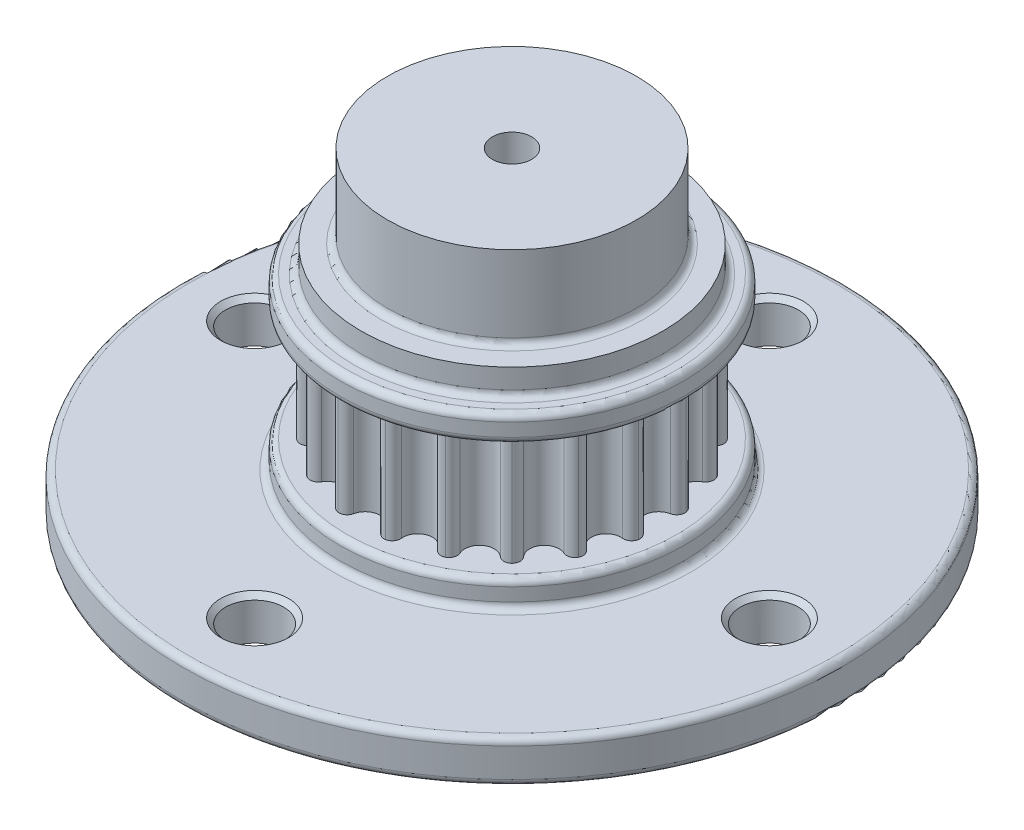
from build123d import *

# Parameters (mm, degrees)
BOSS_EXTRUDE1_DEPTH     = 3.556
CIRPATTERN1_COUNT       = 20
SKETCH2_W               = 10.342329408
SKETCH2_H               = 1.5875
SKETCH9_R               = 19.84375
SKETCH9_R_2             = 1.5
BOSS_EXTRUDE2_DEPTH     = 2.54
SKETCH3_R               = 1.74625
CUT_EXTRUDE1_DEPTH      = 6.087499985
CUT_EXTRUDE1_DEPTH_BACK = 8.627499985
CIRPATTERN2_COUNT       = 4
SKETCH11_R              = 1.5
CUT_EXTRUDE2_DEPTH      = 6
FILLET1_R               = 0.396875


with BuildPart() as part:
    # Sketch1 → Boss-Extrude1 (new body, symmetric)
    with BuildSketch(Plane(origin=(0, 0, 0), x_dir=(1, 0, 0), z_dir=(0, 1, 0))):
        with BuildLine():
            ThreePointArc((0.872060607, 8.659786465), (0.562967303, 8.148255135), (0, 7.947579308))
            ThreePointArc((0, 7.947579308), (-1.243275317, -7.849731418), (2.45593707, 7.55859709))
            ThreePointArc((2.45593707, 7.55859709), (1.982535589, 7.923417607), (1.846642263, 8.505427895))
            ThreePointArc((1.846642263, 8.505427895), (1.749626992, 8.862101959), (1.434119122, 9.054671776))
            ThreePointArc((1.434119122, 9.054671776), (1.074545959, 8.969024291), (0.872060607, 8.659786465))
        make_face()
    boss_extrude1 = extrude(amount=BOSS_EXTRUDE1_DEPTH, both=True)

    # CirPattern1: Boss-Extrude1 ×20 about axis
    cirpattern1_axis = Axis((0, 0, 0), (0, 1, 0))
    for i in range(1, CIRPATTERN1_COUNT):
        add(boss_extrude1.rotate(cirpattern1_axis, i * 360 / CIRPATTERN1_COUNT))

    # Sketch2 → Revolve3 (revolve)
    with BuildSketch(Plane(origin=(0, 0, 0), x_dir=(0, 0, -1), z_dir=(1, 0, 0))):
        with Locations((5.171164704, 4.293749985)):
            Rectangle(SKETCH2_W, SKETCH2_H)
    revolve3 = revolve(axis=Axis((0, 3.3, 0), (0, -1, 0)))

    # Mirror1: Revolve3 across plane
    add(revolve3.mirror(Plane.ZX))

    # Sketch9 → Boss-Extrude2 (add)
    with BuildSketch(Plane.XZ.offset(5.087499985)):
        Circle(SKETCH9_R)
        Circle(SKETCH9_R_2, mode=Mode.SUBTRACT)
    extrude(amount=BOSS_EXTRUDE2_DEPTH)

    # Sketch3 → Cut-Extrude1 (cut, two sides)
    with BuildSketch(Plane(origin=(0, 0, 0), x_dir=(1, 0, 0), z_dir=(0, 1, 0))) as cut_extrude1_sk:
        with Locations((-15.5, 0)):
            Circle(SKETCH3_R)
        with Locations((0, 15.5)):
            Circle(SKETCH3_R)
        with Locations((15.5, 0)):
            Circle(SKETCH3_R)
        with Locations((0, -15.5)):
            Circle(SKETCH3_R)
    extrude(amount=CUT_EXTRUDE1_DEPTH, mode=Mode.SUBTRACT)
    extrude(cut_extrude1_sk.sketch, amount=-CUT_EXTRUDE1_DEPTH_BACK, mode=Mode.SUBTRACT)

    # Sketch6 → Cut-Revolve2 (revolve, cut)
    with BuildSketch(Plane.XY):
        Polygon((-11.8678, -3.499999985), (-15.5, -7.132199985), (-15.5, -3.499999985), align=None)
    cut_revolve2 = revolve(axis=Axis((-15.5, -7.627499985, 0), (0, 1, 0)), mode=Mode.SUBTRACT)

    # CirPattern2: Cut-Revolve2 ×4 about axis
    cirpattern2_axis = Axis((0, 0, 0), (0, 1, 0))
    for i in range(1, CIRPATTERN2_COUNT):
        add(cut_revolve2.rotate(cirpattern2_axis, i * 360 / CIRPATTERN2_COUNT), mode=Mode.SUBTRACT)

    # Sketch11 → Cut-Extrude2 (cut)
    with BuildSketch(Plane.XZ.offset(5.087499985)):
        Circle(SKETCH11_R)
    extrude(amount=-CUT_EXTRUDE2_DEPTH, mode=Mode.SUBTRACT)

    # Sketch10 → Revolve4 (revolve)
    with BuildSketch(Plane(origin=(0, 0, 0), x_dir=(0, 0, -1), z_dir=(1, 0, 0))):
        Polygon((1.182175065, 6.674999985), (1.182175065, 11.674999985), (7.5, 11.674999985), (7.5, 6.674999985), (9.0875, 6.674999985), (9.0875, 5.087499985), (1.182175065, 5.087499985), align=None)
    revolve(axis=Axis((0, 0, 0), (0, 1, 0)))

    # Fillet1
    fillet1_edges = [part.edges().sort_by_distance(p)[0] for p in [
        (0, 5.087499985, 10.342329408),
        (0, 3.499999985, 10.342329408),
        (0, -3.499999985, 10.342329408),
        (0, -5.087499985, 10.342329408),
        (-19.84375, -7.627499985, 0),
        (-19.84375, -5.087499985, 0),
        (0, 5.087499985, 9.0875),
        (0, 6.674999985, 7.5),
    ]]
    fillet(fillet1_edges, radius=FILLET1_R)


solid = part.part
